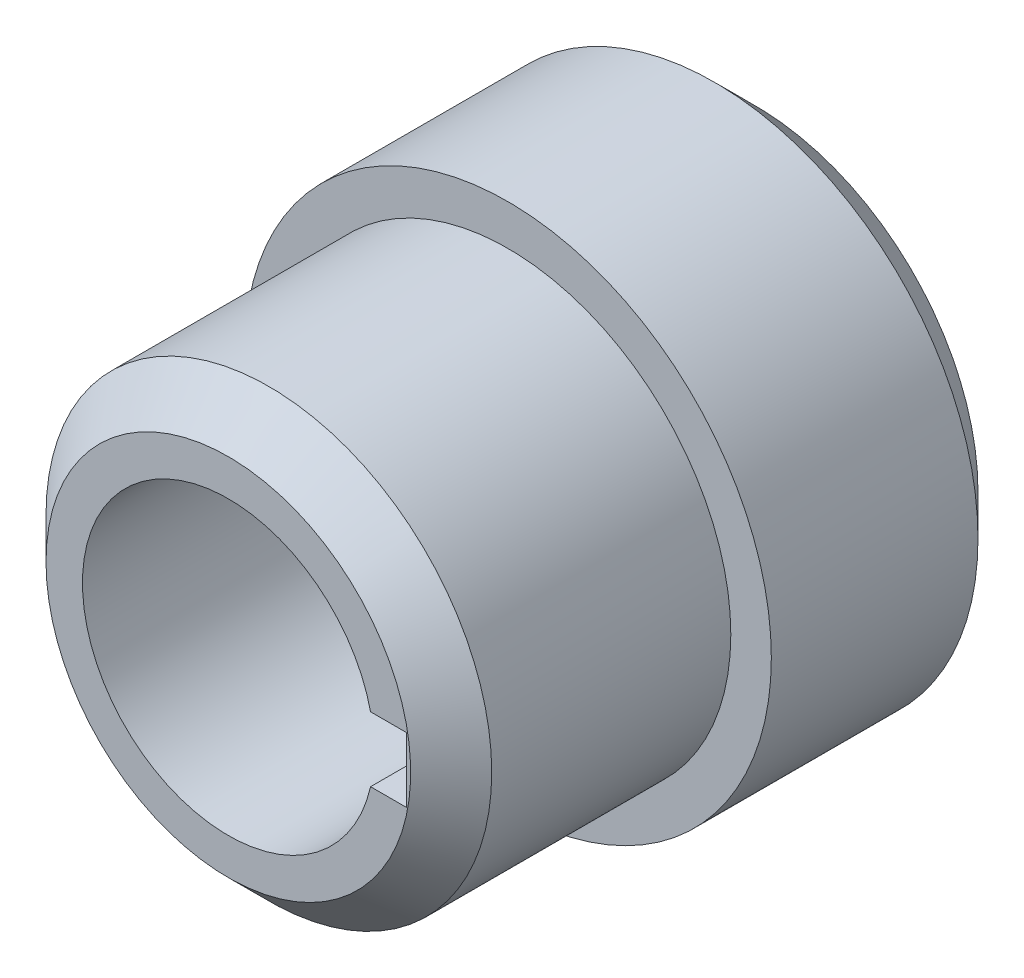
from build123d import *

# Parameters (mm, degrees)
ZKOSEN_1_SIZE            = 5
ZKOSEN_2_SIZE            = 5
SKICA3_W                 = 8
SKICA3_H                 = 8
ODEBRAT_VYSUNUT_M1_DEPTH = 66


with BuildPart() as part:
    # Skica1 → Rotovat1 (revolve)
    with BuildSketch(Plane(origin=(0, 0, 0), x_dir=(0, 0, -1), z_dir=(1, 0, 0))):
        Polygon((0, 18), (0, 27.5), (34.5, 27.5), (34.5, 32.5), (65, 32.5), (65, 18), align=None)
    revolve(axis=Axis((0, 0, 25.517724518), (0, 0, -1)))

    # Zkosení1
    zkosen_1_edges = [part.edges().sort_by_distance(p)[0] for p in [
        (0, -27.5, 0),
    ]]
    chamfer(zkosen_1_edges, length=ZKOSEN_1_SIZE)

    # Zkosení2
    zkosen_2_edges = [part.edges().sort_by_distance(p)[0] for p in [
        (0, -32.5, -65),
    ]]
    chamfer(zkosen_2_edges, length=ZKOSEN_2_SIZE)

    # Skica3 → Odebrat vysunutím1 (cut, through all)
    with BuildSketch(Plane.XY):
        with Locations((18, 0)):
            Rectangle(SKICA3_W, SKICA3_H)
    extrude(amount=-ODEBRAT_VYSUNUT_M1_DEPTH, mode=Mode.SUBTRACT)


solid = part.part
